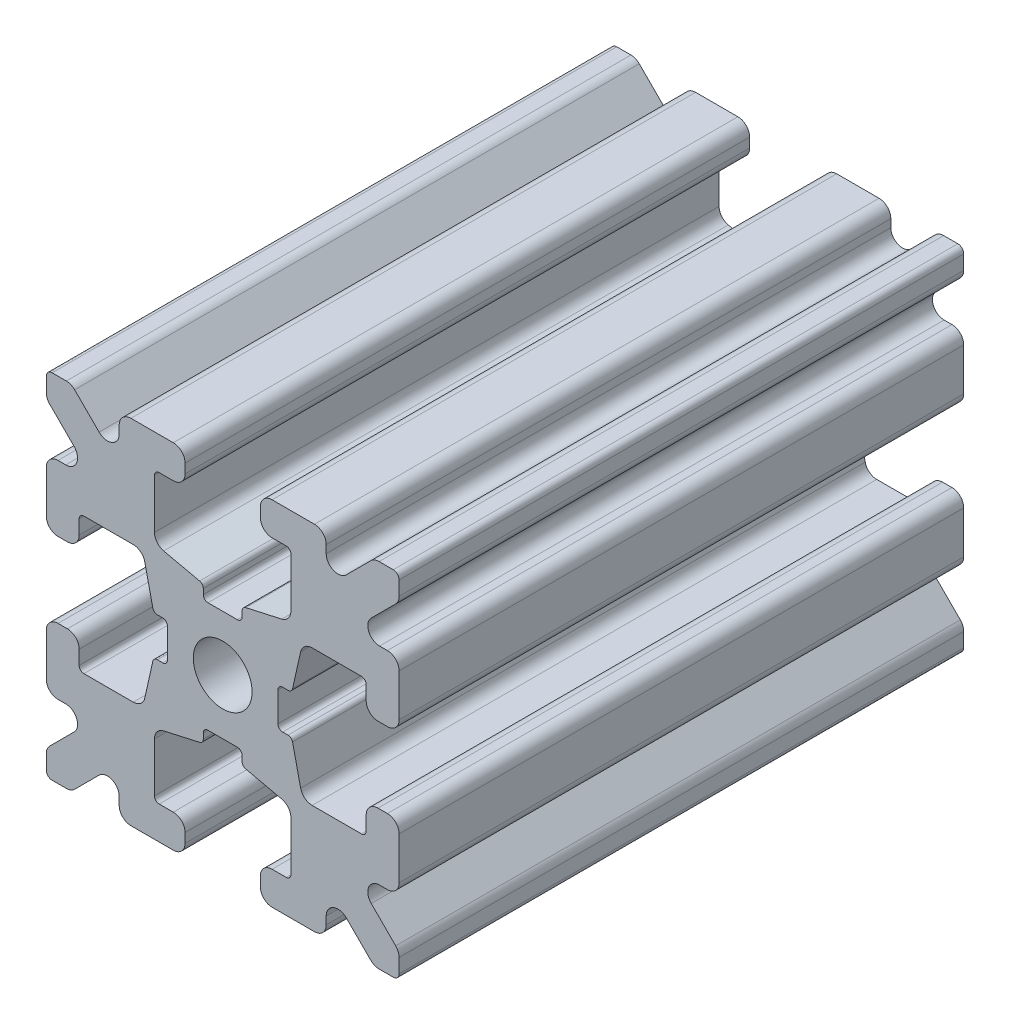
from build123d import *

# Parameters (mm, degrees)
SKETCH1_W           = 15
SKETCH1_H           = 15
SKETCH1_R           = 1.25
BOSS_EXTRUDE1_DEPTH = 12
FILLET1_R           = 0.25
CUT_EXTRUDE1_DEPTH  = 25
CUT_EXTRUDE3_DEPTH  = 25
FILLET3_R           = 0.5
FILLET4_R           = 0.5
FILLET5_R           = 3
FILLET6_R           = 0.2
CUT_EXTRUDE4_DEPTH  = 25
FILLET8_R           = 0.5
SKETCH6_W           = 5.1529354
SKETCH6_H           = 1.651
SKETCH6_W_2         = 1.651
SKETCH6_H_2         = 5.1529354
CUT_EXTRUDE5_DEPTH  = 25
FILLET10_R          = 0.2


with BuildPart() as part:
    # Sketch1 → Boss-Extrude1 (new body, symmetric)
    with BuildSketch(Plane.XY):
        Rectangle(SKETCH1_W, SKETCH1_H)
        Circle(SKETCH1_R, mode=Mode.SUBTRACT)
    extrude(amount=BOSS_EXTRUDE1_DEPTH, both=True)

    # Fillet1
    fillet1_edges = [part.edges().sort_by_distance(p)[0] for p in [
        (7.5, -7.5, 0),
        (-7.5, -7.5, 0),
        (-7.5, 7.5, 0),
        (7.5, 7.5, 0),
    ]]
    fillet(fillet1_edges, radius=FILLET1_R)

    # Sketch2 → Cut-Extrude1 (cut, through all)
    with BuildSketch(Plane.XY.offset(12)):
        Polygon((-7.5, 1.6), (-6.1, 1.6), (-6.1, 2.9), (-3.4, 2.9), (-3.4, -2.9), (-6.1, -2.9), (-6.1, -1.6), (-7.5, -1.6), align=None)
        Polygon((2.9, 6.1), (1.6, 6.1), (1.6, 7.5), (-1.6, 7.5), (-1.6, 6.1), (-2.9, 6.1), (-2.9, 3.4), (2.9, 3.4), align=None)
        Polygon((-1.6, -7.5), (-1.6, -6.1), (-2.9, -6.1), (-2.9, -3.4), (2.9, -3.4), (2.9, -6.1), (1.6, -6.1), (1.6, -7.5), align=None)
        Polygon((6.1, -2.9), (6.1, -1.6), (7.5, -1.6), (7.5, 1.6), (6.1, 1.6), (6.1, 2.9), (3.4, 2.9), (3.4, -2.9), align=None)
    extrude(amount=-CUT_EXTRUDE1_DEPTH, mode=Mode.SUBTRACT)

    # Sketch4 → Cut-Extrude3 (cut, through all)
    with BuildSketch(Plane.XY.offset(12)):
        Polygon((-3.4, 2.9), (-2.75, 0), (-3.4, -2.9), align=None)
        Polygon((-2.9, 3.4), (0, 2.75), (2.9, 3.4), align=None)
        Polygon((3.4, 2.9), (2.75, 0), (3.4, -2.9), align=None)
        Polygon((-2.9, -3.4), (0, -2.75), (2.9, -3.4), align=None)
    extrude(amount=-CUT_EXTRUDE3_DEPTH, mode=Mode.SUBTRACT)

    # Fillet3
    fillet3_edges = [part.edges().sort_by_distance(p)[0] for p in [
        (1.6, -7.5, 0),
        (-1.6, -7.5, 0),
        (-1.6, -6.1, 0),
        (1.6, -6.1, 0),
        (6.1, 1.6, 0),
        (7.5, 1.6, 0),
        (7.5, -1.6, 0),
        (6.1, -1.6, 0),
        (-7.5, -1.6, 0),
        (-7.5, 1.6, 0),
        (-6.1, 1.6, 0),
        (-6.1, -1.6, 0),
        (-1.6, 6.1, 0),
        (-1.6, 7.5, 0),
        (1.6, 7.5, 0),
        (1.6, 6.1, 0),
    ]]
    fillet(fillet3_edges, radius=FILLET3_R)

    # Fillet4
    fillet4_edges = [part.edges().sort_by_distance(p)[0] for p in [
        (-2.9, -3.4, 0),
        (2.9, -3.4, 0),
        (3.4, -2.9, 0),
        (3.4, 2.9, 0),
        (-3.4, 2.9, 0),
        (-3.4, -2.9, 0),
        (2.9, 3.4, 0),
        (-2.9, 3.4, 0),
    ]]
    fillet(fillet4_edges, radius=FILLET4_R)

    # Fillet5
    fillet5_edges = [part.edges().sort_by_distance(p)[0] for p in [
        (-2.75, 0, 0),
        (0, 2.75, 0),
        (2.75, 0, 0),
        (0, -2.75, 0),
    ]]
    fillet(fillet5_edges, radius=FILLET5_R)

    # Fillet6
    fillet6_edges = [part.edges().sort_by_distance(p)[0] for p in [
        (-2.9, -6.1, 0),
        (2.9, -6.1, 0),
        (6.1, -2.9, 0),
        (6.1, 2.9, 0),
        (-6.1, 2.9, 0),
        (-6.1, -2.9, 0),
        (2.9, 6.1, 0),
        (-2.9, 6.1, 0),
    ]]
    fillet(fillet6_edges, radius=FILLET6_R)

    # Sketch5 → Cut-Extrude4 (cut, through all)
    with BuildSketch(Plane.XY.offset(12)):
        Polygon((-7.5, 6.439339828), (-5.460660172, 4.4), (-7.5, 4.4), align=None)
        Polygon((-6.439339828, 7.5), (-4.4, 5.460660172), (-4.4, 7.5), align=None)
        Polygon((4.4, 7.5), (6.439339828, 7.5), (4.4, 5.460660172), align=None)
        Polygon((7.5, 6.439339828), (7.5, 4.4), (5.460660172, 4.4), align=None)
        Polygon((7.5, -6.439339828), (5.460660172, -4.4), (7.5, -4.4), align=None)
        Polygon((6.439339828, -7.5), (4.4, -5.460660172), (4.4, -7.5), align=None)
        Polygon((-4.4, -7.5), (-6.439339828, -7.5), (-4.4, -5.460660172), align=None)
        Polygon((-7.5, -6.439339828), (-7.5, -4.4), (-5.460660172, -4.4), align=None)
    extrude(amount=-CUT_EXTRUDE4_DEPTH, mode=Mode.SUBTRACT)

    # Fillet8
    fillet8_edges = [part.edges().sort_by_distance(p)[0] for p in [
        (-7.5, 4.4, 0),
        (-7.5, 6.439339828, 0),
        (-5.460660172, 4.4, 0),
        (7.5, -4.4, 0),
        (7.5, -6.439339828, 0),
        (5.460660172, -4.4, 0),
        (5.460660172, 4.4, 0),
        (7.5, 6.439339828, 0),
        (7.5, 4.4, 0),
        (-4.4, 7.5, 0),
        (-4.4, 5.460660172, 0),
        (-6.439339828, 7.5, 0),
        (-5.460660172, -4.4, 0),
        (-7.5, -6.439339828, 0),
        (-7.5, -4.4, 0),
        (4.4, 5.460660172, 0),
        (4.4, 7.5, 0),
        (6.439339828, 7.5, 0),
        (6.439339828, -7.5, 0),
        (4.4, -7.5, 0),
        (4.4, -5.460660172, 0),
        (-6.439339828, -7.5, 0),
        (-4.4, -5.460660172, 0),
        (-4.4, -7.5, 0),
    ]]
    fillet(fillet8_edges, radius=FILLET8_R)

    # Sketch6 → Cut-Extrude5 (cut, through all)
    with BuildSketch(Plane.XY.offset(12)):
        with Locations((4.9235323, 0)):
            Rectangle(SKETCH6_W, SKETCH6_H)
        with Locations((0, -4.9235323)):
            Rectangle(SKETCH6_W_2, SKETCH6_H_2)
        with Locations((-4.9235323, 0)):
            Rectangle(SKETCH6_W, SKETCH6_H)
        with Locations((0, 4.9235323)):
            Rectangle(SKETCH6_W_2, SKETCH6_H_2)
    extrude(amount=-CUT_EXTRUDE5_DEPTH, mode=Mode.SUBTRACT)

    # Fillet10
    fillet10_edges = [part.edges().sort_by_distance(p)[0] for p in [
        (0.8255, -2.935025862, 0),
        (-0.8255, -2.935025862, 0),
        (0.8255, -2.3470646, 0),
        (-0.8255, -2.3470646, 0),
        (2.935025862, 0.8255, 0),
        (2.935025862, -0.8255, 0),
        (2.3470646, 0.8255, 0),
        (2.3470646, -0.8255, 0),
        (-2.935025862, -0.8255, 0),
        (-2.935025862, 0.8255, 0),
        (-2.3470646, -0.8255, 0),
        (-2.3470646, 0.8255, 0),
        (-0.8255, 2.935025862, 0),
        (0.8255, 2.935025862, 0),
        (-0.8255, 2.3470646, 0),
        (0.8255, 2.3470646, 0),
    ]]
    fillet(fillet10_edges, radius=FILLET10_R)


solid = part.part
